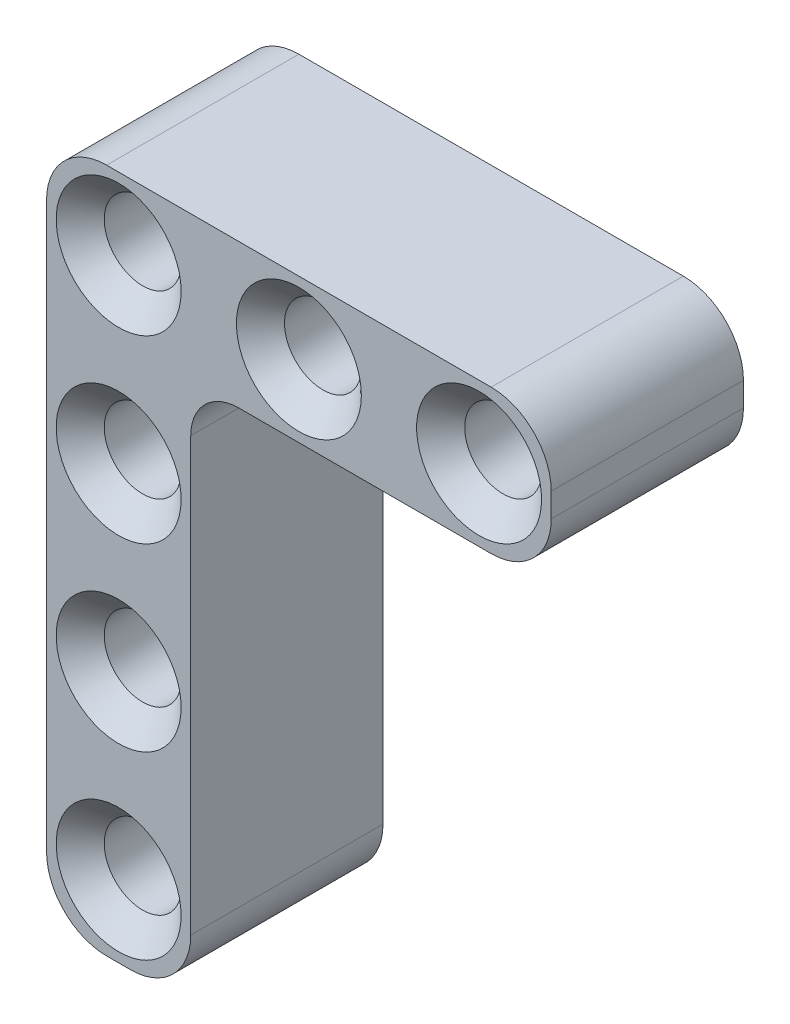
from build123d import *

# Parameters (mm, degrees)
SKETCH1_R           = 1.6
BOSS_EXTRUDE1_DEPTH = 8
CHAMFER1_SIZE       = 1
SKETCH2_R           = 1.6
BOSS_EXTRUDE3_DEPTH = 8
FILLET1_R           = 2
CHAMFER5_SIZE       = 1


with BuildPart() as part:
    # Sketch1 → Boss-Extrude1 (new body)
    with BuildSketch(Plane.XY):
        with BuildLine():
            Line((-0.5, 3), (15.5, 3))
            ThreePointArc((15.5, 3), (17.267766953, 2.267766953), (18, 0.5))
            Line((18, 0.5), (18, -0.5))
            ThreePointArc((18, -0.5), (17.267766953, -2.267766953), (15.5, -3))
            Line((15.5, -3), (-0.5, -3))
            ThreePointArc((-0.5, -3), (-2.267766953, -2.267766953), (-3, -0.5))
            Line((-3, -0.5), (-3, 0.5))
            ThreePointArc((-3, 0.5), (-2.267766953, 2.267766953), (-0.5, 3))
        make_face()
        Circle(SKETCH1_R, mode=Mode.SUBTRACT)
        with Locations((7.5, 0)):
            Circle(SKETCH1_R, mode=Mode.SUBTRACT)
        with Locations((15, 0)):
            Circle(SKETCH1_R, mode=Mode.SUBTRACT)
    extrude(amount=BOSS_EXTRUDE1_DEPTH)

    # Chamfer1
    chamfer1_edges = [part.edges().sort_by_distance(p)[0] for p in [
        (-1.6, 0, 0),
        (-1.6, 0, 8),
        (5.9, 0, 0),
        (5.9, 0, 8),
        (13.4, 0, 0),
        (13.4, 0, 8),
    ]]
    chamfer(chamfer1_edges, length=CHAMFER1_SIZE)

    # Sketch2 → Boss-Extrude3 (add)
    with BuildSketch(Plane.XY.offset(8)):
        with BuildLine():
            ThreePointArc((-0.5, -3), (-2.267766953, -2.267766953), (-3, -0.5))
            Line((-3, -0.5), (-3, -23))
            ThreePointArc((-3, -23), (-2.267766953, -24.767766953), (-0.5, -25.5))
            Line((-0.5, -25.5), (0.5, -25.5))
            ThreePointArc((0.5, -25.5), (2.267766953, -24.767766953), (3, -23))
            Line((3, -23), (3, -3))
            Line((3, -3), (-0.5, -3))
        make_face()
        with Locations((0, -22.5)):
            Circle(SKETCH2_R, mode=Mode.SUBTRACT)
        with Locations((0, -15)):
            Circle(SKETCH2_R, mode=Mode.SUBTRACT)
        with Locations((0, -7.5)):
            Circle(SKETCH2_R, mode=Mode.SUBTRACT)
    extrude(amount=-BOSS_EXTRUDE3_DEPTH)

    # Fillet1
    fillet1_edges = [part.edges().sort_by_distance(p)[0] for p in [
        (3, -3, 4),
    ]]
    fillet(fillet1_edges, radius=FILLET1_R)

    # Chamfer5
    chamfer5_edges = [part.edges().sort_by_distance(p)[0] for p in [
        (-1.6, -7.5, 8),
        (-1.6, -15, 8),
        (-1.6, -22.5, 8),
        (-1.6, -22.5, 0),
        (-1.6, -15, 0),
        (-1.6, -7.5, 0),
    ]]
    chamfer(chamfer5_edges, length=CHAMFER5_SIZE)


solid = part.part
